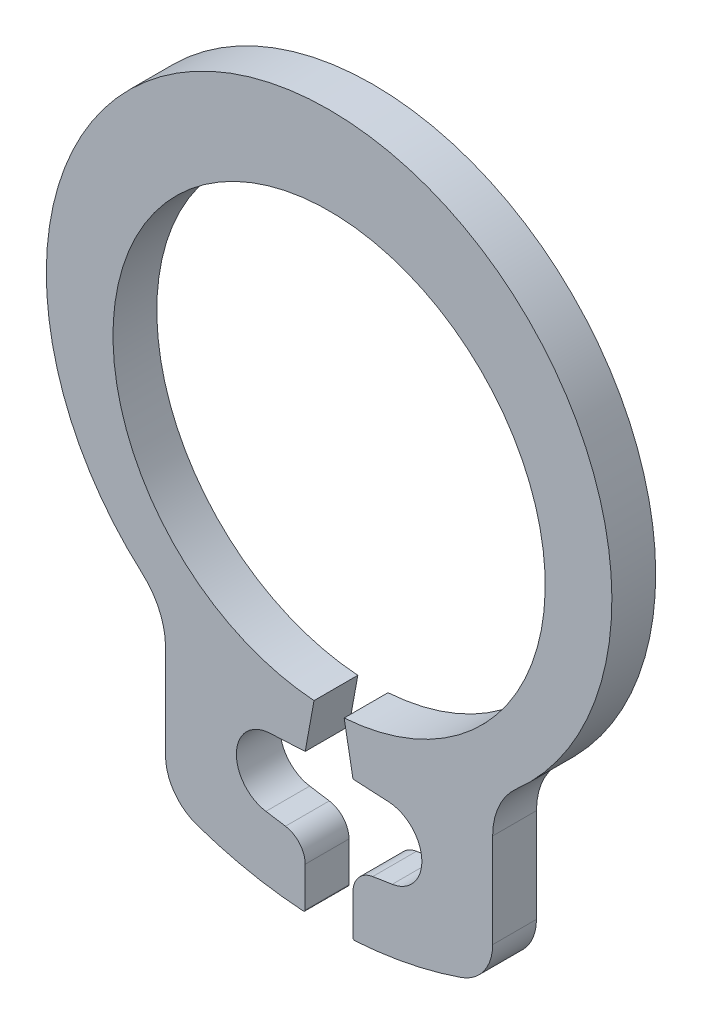
from build123d import *

# Parameters (mm, degrees)
BOSS_EXTRUDE1_DEPTH = 0.375


with BuildPart() as part:
    # Sketch3 → Boss-Extrude1 (new, symmetric)
    with BuildSketch(Plane.XY):
        with BuildLine():
            Line((-2.800142094, -5.780594647), (-2.800142094, -4.16896088))
            ThreePointArc((-2.800142094, -4.16896088), (-2.906194065, -3.675728978), (-3.205604942, -3.269677435))
            ThreePointArc((-3.205604942, -3.269677435), (-4.528005601, 2.072292656), (0, 5.2))
            Line((0, 5.2), (0, 3.7))
            ThreePointArc((0, 3.7), (-3.69774606, 0.129128138), (-0.258098953, -3.690986986))
            Line((-0.258098953, -3.690986986), (-0.409154928, -4.520936126))
            Line((-0.409154928, -4.520936126), (-1.019085782, -4.552901247))
            ThreePointArc((-1.019085782, -4.552901247), (-1.586861929, -5.120677394), (-1.081544887, -5.744691972))
            Line((-1.081544887, -5.744691972), (-0.746581142, -5.797745018))
            ThreePointArc((-0.746581142, -5.797745018), (-0.504992542, -5.933041134), (-0.409154928, -6.192820354))
            Line((-0.409154928, -6.192820354), (-0.409154928, -6.870700795))
            ThreePointArc((-0.409154928, -6.870700795), (-0.419264451, -6.894041896), (-0.443205367, -6.902635035))
            ThreePointArc((-0.443205367, -6.902635035), (-1.364795043, -6.780865425), (-2.261733258, -6.536617175))
            ThreePointArc((-2.261733258, -6.536617175), (-2.651783457, -6.244667416), (-2.800142094, -5.780594647))
        make_face()
    extrude(amount=BOSS_EXTRUDE1_DEPTH, both=True)

    # Mirror1: part across plane


with BuildPart() as part_1:
    add(part.part)
    add(part.part.mirror(Plane(origin=(0, 5.2, 0.375), x_dir=(0, 0, 1), z_dir=(-1, 0, 0))))


solid = part_1.part
